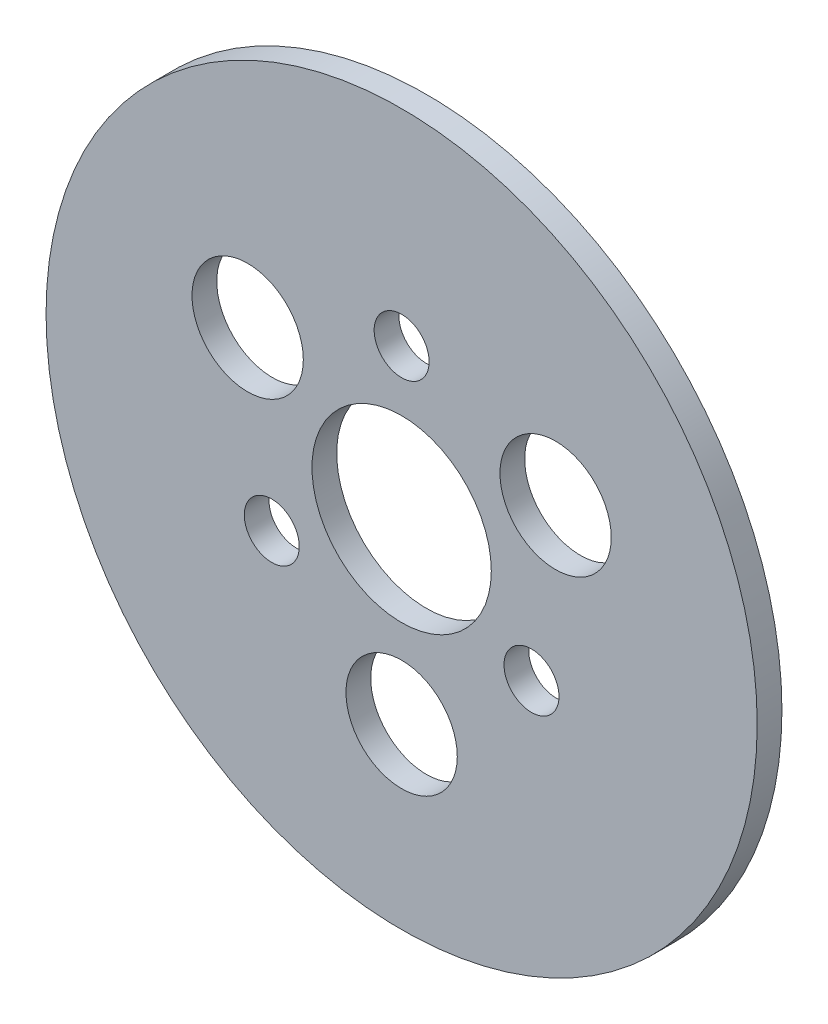
from build123d import *

# Parameters (mm, degrees)
SKETCH1_R           = 57.5
SKETCH1_R_2         = 14.5
SKETCH1_R_3         = 4.445
SKETCH1_R_4         = 9
BOSS_EXTRUDE1_DEPTH = 2


with BuildPart() as part:
    # Sketch1 → Boss-Extrude1 (new body, symmetric)
    with BuildSketch(Plane.XY):
        Circle(SKETCH1_R)
        Circle(SKETCH1_R_2, mode=Mode.SUBTRACT)
        with Locations((0, 24.248711306)):
            Circle(SKETCH1_R_3, mode=Mode.SUBTRACT)
        with Locations((-21, -12.124355653)):
            Circle(SKETCH1_R_3, mode=Mode.SUBTRACT)
        with Locations((21, -12.124355653)):
            Circle(SKETCH1_R_3, mode=Mode.SUBTRACT)
        with Locations((-24.898230359, 14.375)):
            Circle(SKETCH1_R_4, mode=Mode.SUBTRACT)
        with Locations((24.898230359, 14.375)):
            Circle(SKETCH1_R_4, mode=Mode.SUBTRACT)
        with Locations((0, -28.75)):
            Circle(SKETCH1_R_4, mode=Mode.SUBTRACT)
    extrude(amount=BOSS_EXTRUDE1_DEPTH, both=True)


solid = part.part
